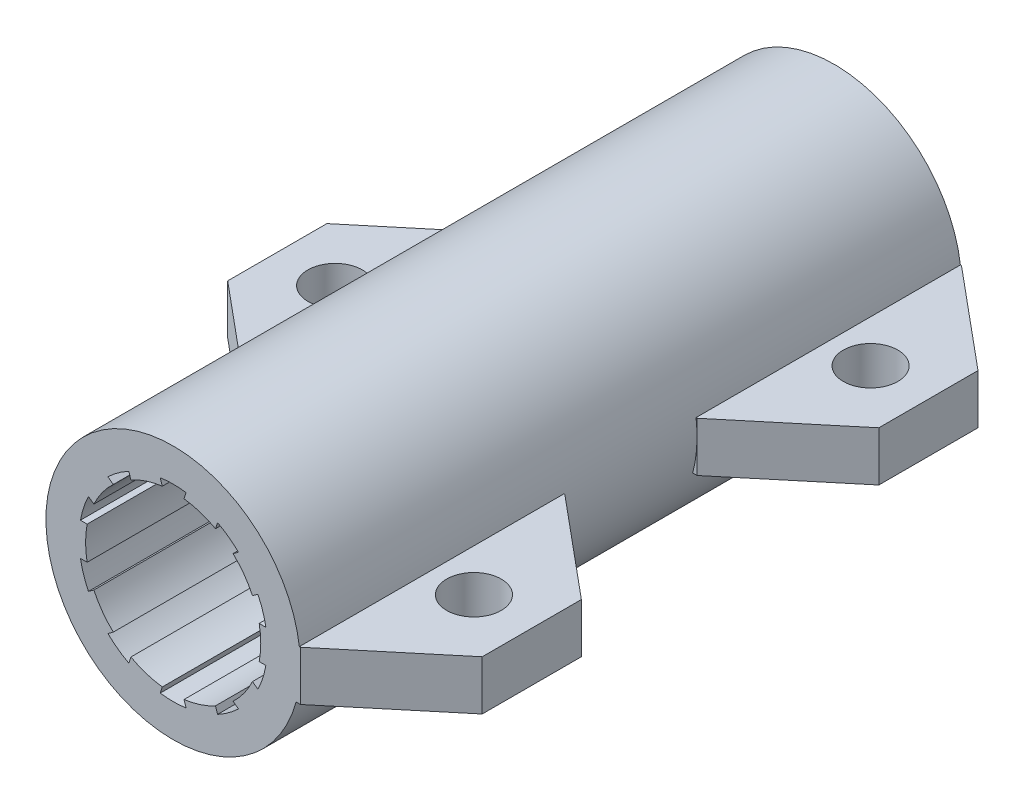
from build123d import *

# Parameters (mm, degrees)
ESBO_O1_R                     = 7.7
ESBO_O1_R_2                   = 5.7
RESSALTO_EXTRUS_O1_DEPTH      = 40
RESSALTO_EXTRUS_O3_DEPTH      = 1
RESSALTO_EXTRUS_O3_DEPTH_BACK = 2
ESBO_O4_R                     = 1.65
CORTE_EXTRUS_O1_DEPTH         = 9.7
ESBO_O5_W                     = 3.890243015
ESBO_O5_H                     = 2
RESSALTO_EXTRUS_O4_DEPTH      = 40
PADR_OCIRCULAR1_COUNT         = 10
ESBO_O6_R                     = 5.3
CORTE_EXTRUS_O2_DEPTH         = 41


with BuildPart() as part:
    # Esboço1 → Ressalto-extrusão1 (new body)
    with BuildSketch(Plane.XY):
        Circle(ESBO_O1_R)
        Circle(ESBO_O1_R_2, mode=Mode.SUBTRACT)
    extrude(amount=RESSALTO_EXTRUS_O1_DEPTH)

    # Esboço3 → Ressalto-extrusão3 (add, two sides)
    with BuildSketch(Plane(origin=(0, 0, 0), x_dir=(1, 0, 0), z_dir=(0, 1, 0))) as ressalto_extrus_o3_sk:
        Polygon((7.7, -40), (13.7, -35), (13.7, -29), (7.7, -24), (6.7, -24), (6.7, -40), align=None)
        Polygon((7.7, 0), (13.7, -5), (13.7, -11), (7.7, -16), (6.7, -16), (6.7, 0), align=None)
        Polygon((-7.7, -28), (-13.7, -23), (-13.7, -17), (-7.7, -12), (-6.7, -12), (-6.7, -28), align=None)
    extrude(amount=RESSALTO_EXTRUS_O3_DEPTH)
    extrude(ressalto_extrus_o3_sk.sketch, amount=-RESSALTO_EXTRUS_O3_DEPTH_BACK)

    # Esboço4 → Corte-extrusão1 (cut, through all)
    with BuildSketch(Plane(origin=(0, 1, 0), x_dir=(1, 0, 0), z_dir=(0, 1, 0))):
        with Locations((10.2, -32)):
            Circle(ESBO_O4_R)
        with Locations((10.2, -8)):
            Circle(ESBO_O4_R)
        with Locations((-10.2, -20)):
            Circle(ESBO_O4_R)
    extrude(amount=-CORTE_EXTRUS_O1_DEPTH, mode=Mode.SUBTRACT)

    # Esboço5 → Ressalto-extrusão4 (add)
    with BuildSketch(Plane.XY.offset(40)):
        with Locations((-4.945121507, 0)):
            Rectangle(ESBO_O5_W, ESBO_O5_H)
    ressalto_extrus_o4 = extrude(amount=-RESSALTO_EXTRUS_O4_DEPTH)

    # PadrãoCircular1: Ressalto-extrusão4 ×10 about axis
    padr_ocircular1_axis = Axis((0, 0, 0), (0, 0, 1))
    for i in range(1, PADR_OCIRCULAR1_COUNT):
        add(ressalto_extrus_o4.rotate(padr_ocircular1_axis, i * 360 / PADR_OCIRCULAR1_COUNT))

    # Esboço6 → Corte-extrusão2 (cut, through all)
    with BuildSketch(Plane.XY.offset(40)):
        Circle(ESBO_O6_R)
    extrude(amount=-CORTE_EXTRUS_O2_DEPTH, mode=Mode.SUBTRACT)


solid = part.part
